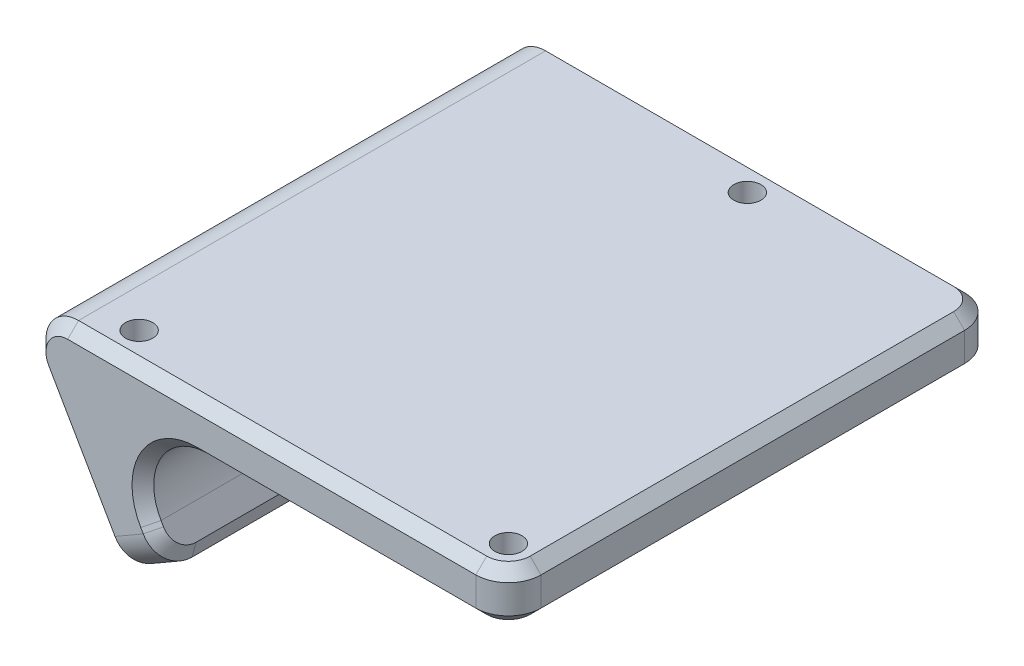
from build123d import *

# Parameters (mm, degrees)
EXTRUDE_1_DEPTH        = 45
FILLET_1_R             = 3
FILLET_2_R             = 5
FILLET_3_R             = 3
FILLET_4_R             = 3
CHAMFER_1_SIZE         = 1
HOLE_WIZARD_M3_1_D     = 2.5
HOLE_WIZARD_M3_1_DEPTH = 7.5
HOLE_WIZARD_M3_1_TIP   = 0.751075774
CHAMFER_2_SIZE         = 1
HOLE_WIZARD_M3_2_D     = 2.5
HOLE_WIZARD_M3_2_DEPTH = 7.5
HOLE_WIZARD_M3_2_TIP   = 0.751075774


with BuildPart() as part:
    # 草图1 → 凸台-拉伸1 (new body)
    with BuildSketch(Plane.XY):
        Polygon((40, 0), (-5.773502692, 0), (4.411675645, -17.641246358), (8.741802661, -15.141246359), (2.685178332, -4.650865298), (40, -4.650865298), align=None)
    extrude(amount=-EXTRUDE_1_DEPTH)

    # 圆角1
    fillet_1_edges = [part.edges().sort_by_distance(p)[0] for p in [
        (40, -2.325432649, -45),
        (40, -2.325432649, 0),
    ]]
    fillet(fillet_1_edges, radius=FILLET_1_R)

    # 圆角2
    fillet_2_edges = [part.edges().sort_by_distance(p)[0] for p in [
        (2.685178332, -4.650865298, -22.5),
    ]]
    fillet(fillet_2_edges, radius=FILLET_2_R)

    # 圆角3
    fillet_3_edges = [part.edges().sort_by_distance(p)[0] for p in [
        (-5.773502692, 0, -22.5),
    ]]
    fillet(fillet_3_edges, radius=FILLET_3_R)

    # 圆角4
    fillet_4_edges = [part.edges().sort_by_distance(p)[0] for p in [
        (6.576739153, -16.391246359, -45),
        (6.576739153, -16.391246359, 0),
    ]]
    fillet(fillet_4_edges, radius=FILLET_4_R)

    # 倒角1
    chamfer_1_edges = [part.edges().sort_by_distance(p)[0] for p in [
        (40, -4.650865298, -22.5),
        (24.172716185, -4.650865298, -45),
        (39.121320344, -4.650865298, -44.121320344),
        (39.121320344, -4.650865298, -0.878679656),
        (7.128554006, -12.347017723, -45),
        (24.172716185, -4.650865298, 0),
        (7.01530535, -7.150865298, 0),
        (7.01530535, -7.150865298, -45),
        (8.741802661, -15.141246359, -22.5),
        (7.128554006, -12.347017723, 0),
        (8.302462833, -14.380287455, -0.878679656),
        (8.302462833, -14.380287455, -44.121320344),
    ]]
    chamfer(chamfer_1_edges, length=CHAMFER_1_SIZE)

    # M3 螺纹孔1
    with Locations(Plane(origin=(0, 0, 0), x_dir=(1, 0, 0), z_dir=(0, 1, 0))):
        with Locations((20, 42), (3, 3), (37, 3)):
            Hole(HOLE_WIZARD_M3_1_D / 2, depth=HOLE_WIZARD_M3_1_DEPTH)
            with Locations((0, 0, -(HOLE_WIZARD_M3_1_DEPTH + HOLE_WIZARD_M3_1_TIP / 2))):  # 118° drill point
                Cone(0, HOLE_WIZARD_M3_1_D / 2, HOLE_WIZARD_M3_1_TIP, mode=Mode.SUBTRACT)

    # 倒角2
    chamfer_2_edges = [part.edges().sort_by_distance(p)[0] for p in [
        (18.211324866, 0, 0),
        (40, 0, -22.5),
        (39.121320344, 0, -44.121320344),
        (39.121320344, 0, -0.878679656),
        (18.211324866, 0, -45),
        (-0.131875417, -9.771585074, 0),
        (-3.17542648, -1.5, 0),
        (-3.17542648, -1.5, -45),
        (-0.131875417, -9.771585074, -45),
        (4.411675645, -17.641246358, -22.5),
        (3.972335817, -16.880287454, -0.878679656),
        (3.972335817, -16.880287454, -44.121320344),
    ]]
    chamfer(chamfer_2_edges, length=CHAMFER_2_SIZE)

    # M3 螺纹孔2
    with Locations(Plane(origin=(-4.330127018, -2.5, 0), x_dir=(0, 0, 1), z_dir=(-0.866025404, -0.5, 0))):
        with Locations((-38.625, -8.3965032), (-33.25, -4.3965032), (-27.875, -8.3965032), (-22.5, -12.3965032), (-17.125, -8.3965032), (-11.75, -4.3965032), (-6.375, -8.3965032)):
            Hole(HOLE_WIZARD_M3_2_D / 2, depth=HOLE_WIZARD_M3_2_DEPTH)
            with Locations((0, 0, -(HOLE_WIZARD_M3_2_DEPTH + HOLE_WIZARD_M3_2_TIP / 2))):  # 118° drill point
                Cone(0, HOLE_WIZARD_M3_2_D / 2, HOLE_WIZARD_M3_2_TIP, mode=Mode.SUBTRACT)


solid = part.part
